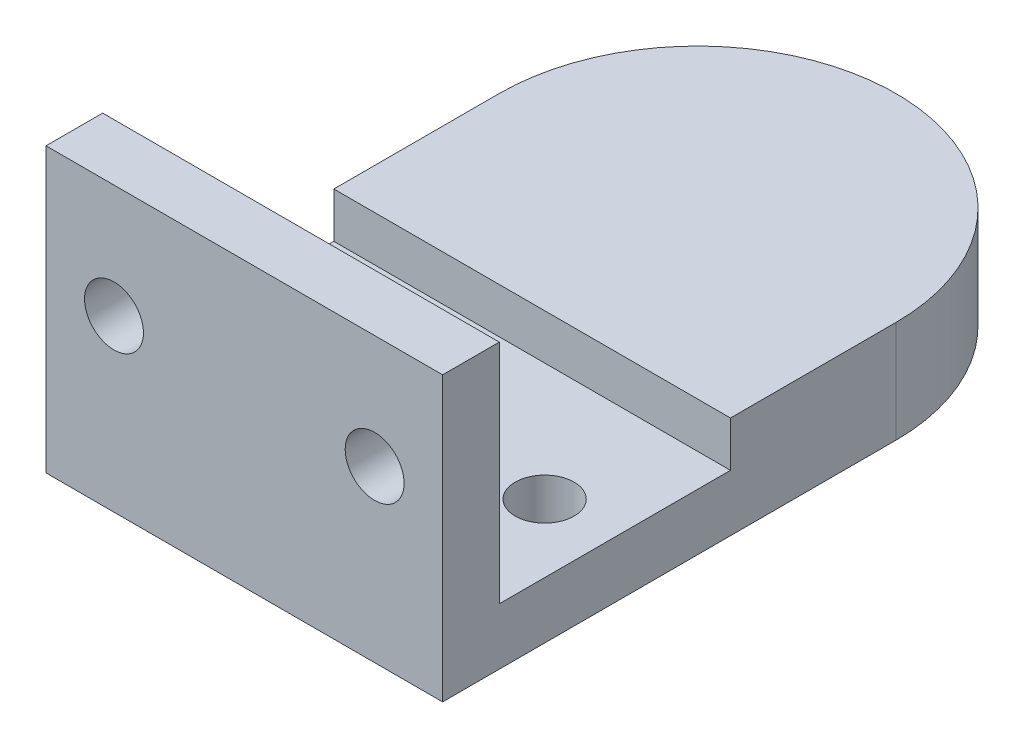
from build123d import *

# Parameters (mm, degrees)
SKETCH1_R           = 11.1
BOSS_EXTRUDE1_DEPTH = 7
SKETCH4_W           = 35
SKETCH4_H           = 20
BOSS_EXTRUDE3_DEPTH = 5
SKETCH5_R           = 2.6
CUT_EXTRUDE1_DEPTH  = 8
BOSS_EXTRUDE4_DEPTH = 2
SKETCH9_W           = 35
SKETCH9_H           = 5
BOSS_EXTRUDE5_DEPTH = 25
SKETCH10_R          = 2.6
CUT_EXTRUDE2_DEPTH  = 25
SKETCH11_W          = 35
SKETCH11_H          = 0.4
CUT_EXTRUDE3_DEPTH  = 4


with BuildPart() as part:
    # Sketch1 → Boss-Extrude1 (new body)
    with BuildSketch(Plane(origin=(0, 0, 0), x_dir=(1, 0, 0), z_dir=(0, 1, 0))):
        with BuildLine():
            Line((-17.5, 0), (-17.5, -15))
            Line((-17.5, -15), (17.5, -15))
            Line((17.5, -15), (17.5, 0))
            ThreePointArc((17.5, 0), (0, 17.5), (-17.5, 0))
        make_face()
        Circle(SKETCH1_R, mode=Mode.SUBTRACT)
    extrude(amount=BOSS_EXTRUDE1_DEPTH)

    # Sketch4 → Boss-Extrude3 (add)
    with BuildSketch(Plane(origin=(0, 0, 0), x_dir=(1, 0, 0), z_dir=(0, 1, 0))):
        with Locations((0, -25)):
            Rectangle(SKETCH4_W, SKETCH4_H)
    extrude(amount=BOSS_EXTRUDE3_DEPTH)

    # Sketch5 → Cut-Extrude1 (cut, through all)
    with BuildSketch(Plane(origin=(0, 7, 0), x_dir=(1, 0, 0), z_dir=(0, 1, 0))):
        with Locations((-11.5, -25)):
            Circle(SKETCH5_R)
        with Locations((11.5, -25)):
            Circle(SKETCH5_R)
    extrude(amount=-CUT_EXTRUDE1_DEPTH, mode=Mode.SUBTRACT)

    # Sketch8 → Boss-Extrude4 (add)
    with BuildSketch(Plane(origin=(0, 7, 0), x_dir=(1, 0, 0), z_dir=(0, 1, 0))):
        with BuildLine():
            Line((-17.5, 0), (-17.5, -15))
            Line((-17.5, -15), (17.5, -15))
            Line((17.5, -15), (17.5, 0))
            ThreePointArc((17.5, 0), (0, 17.5), (-17.5, 0))
        make_face()
    extrude(amount=BOSS_EXTRUDE4_DEPTH)

    # Sketch9 → Boss-Extrude5 (add)
    with BuildSketch(Plane.XZ):
        with Locations((0, 37.5)):
            Rectangle(SKETCH9_W, SKETCH9_H)
    extrude(amount=-BOSS_EXTRUDE5_DEPTH)

    # Sketch10 → Cut-Extrude2 (cut)
    with BuildSketch(Plane(origin=(0, 0, 35), x_dir=(-1, 0, 0), z_dir=(0, 0, -1))):
        with Locations((-11.5, 15)):
            Circle(SKETCH10_R)
        with Locations((11.5, 15)):
            Circle(SKETCH10_R)
    extrude(amount=-CUT_EXTRUDE2_DEPTH, mode=Mode.SUBTRACT)

    # Sketch11 → Cut-Extrude3 (cut)
    with BuildSketch(Plane(origin=(0, 9, 0), x_dir=(1, 0, 0), z_dir=(0, 1, 0))):
        with Locations((0, -14.8)):
            Rectangle(SKETCH11_W, SKETCH11_H)
    extrude(amount=-CUT_EXTRUDE3_DEPTH, mode=Mode.SUBTRACT)


solid = part.part
